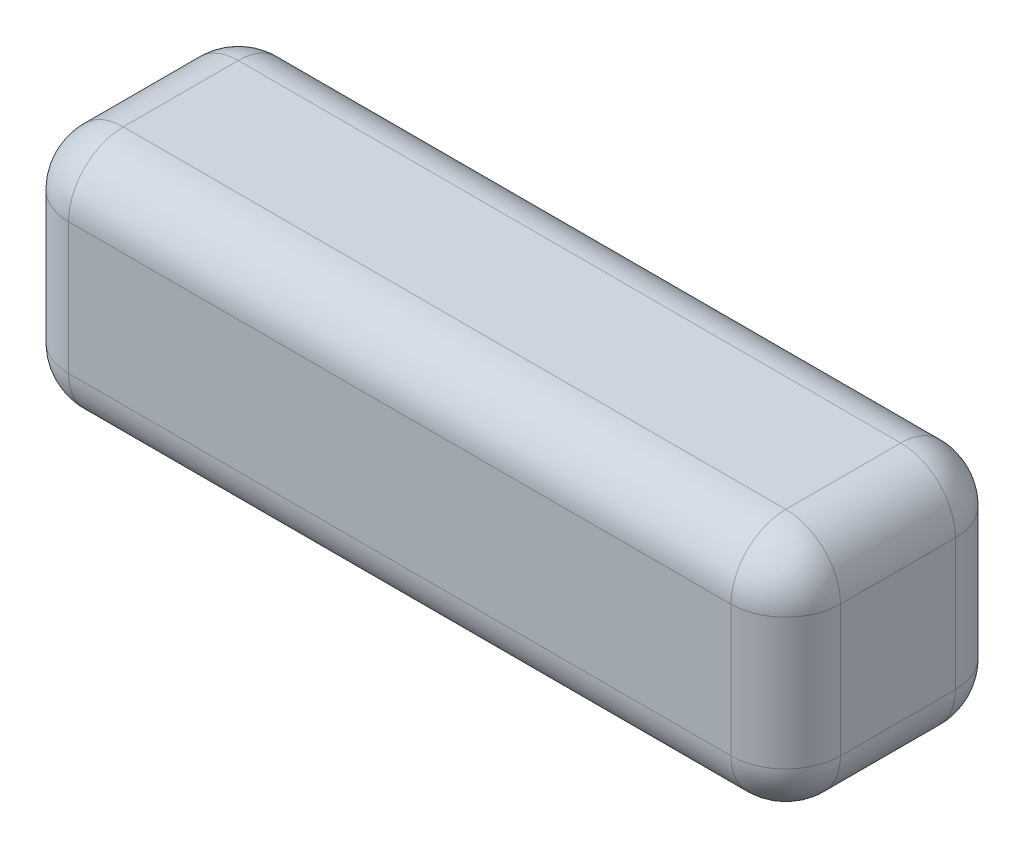
from build123d import *

# Parameters (mm, degrees)
SKETCH1_W           = 141
SKETCH1_H           = 41
BOSS_EXTRUDE1_DEPTH = 44
FILLET1_R           = 10


with BuildPart() as part:
    # Sketch1 → Boss-Extrude1 (new body)
    with BuildSketch(Plane(origin=(0, 0, 0), x_dir=(1, 0, 0), z_dir=(0, 1, 0))):
        Rectangle(SKETCH1_W, SKETCH1_H)
    extrude(amount=BOSS_EXTRUDE1_DEPTH)

    # Fillet1
    fillet1_edges = [part.edges().sort_by_distance(p)[0] for p in [
        (70.5, 44, 0),
        (0, 44, -20.5),
        (-70.5, 44, 0),
        (0, 0, -20.5),
        (70.5, 0, 0),
        (0, 0, 20.5),
        (-70.5, 0, 0),
        (-70.5, 22, -20.5),
        (70.5, 22, -20.5),
        (70.5, 22, 20.5),
        (-70.5, 22, 20.5),
        (0, 44, 20.5),
    ]]
    fillet(fillet1_edges, radius=FILLET1_R)


solid = part.part
